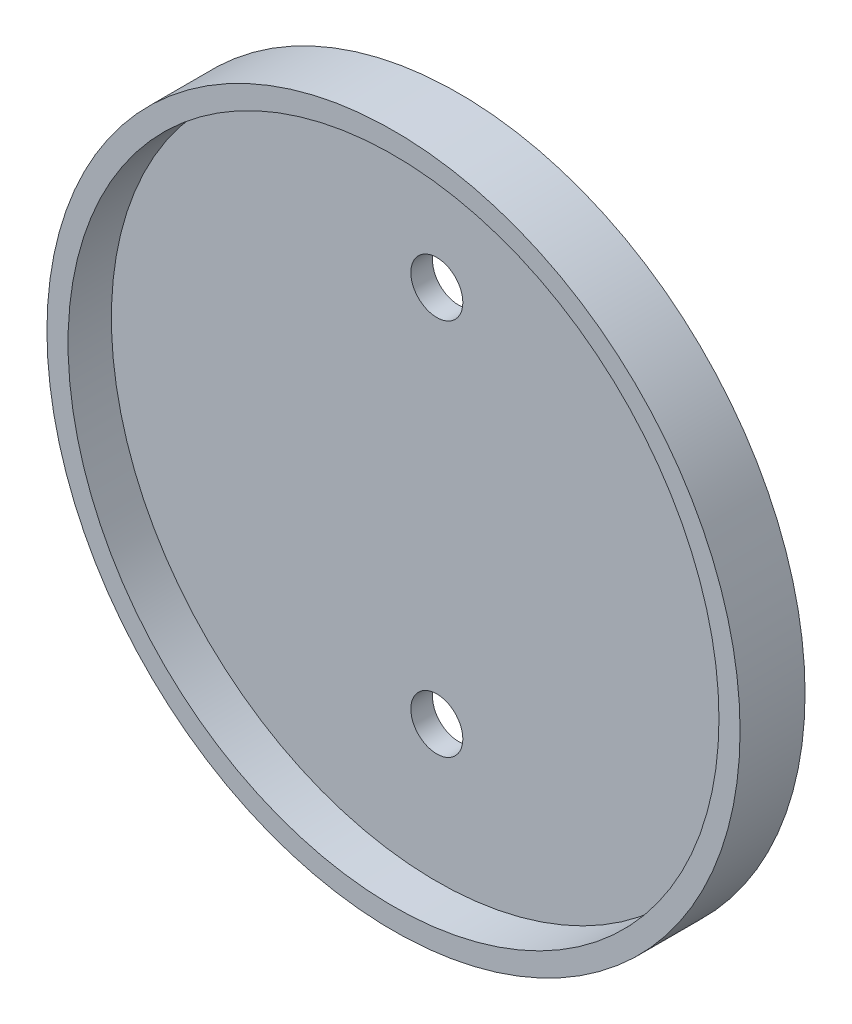
from build123d import *

# Parameters (mm, degrees)
SKETCH1_R                = 32
BOSS_EXTRUDE1_DEPTH      = 0.999998
SKETCH2_R                = 32
SKETCH2_R_2              = 30.05
BOSS_EXTRUDE2_DEPTH      = 4
M4_CLEARANCE_HOLE1_D     = 4.8
M4_CLEARANCE_HOLE1_DEPTH = 1.999996


with BuildPart() as part:
    # Sketch1 → Boss-Extrude1 (new body, symmetric)
    with BuildSketch(Plane.XY):
        Circle(SKETCH1_R)
    extrude(amount=BOSS_EXTRUDE1_DEPTH, both=True)

    # Sketch2 → Boss-Extrude2 (add)
    with BuildSketch(Plane.XY.offset(0.999998)):
        Circle(SKETCH2_R)
        Circle(SKETCH2_R_2, mode=Mode.SUBTRACT)
    extrude(amount=BOSS_EXTRUDE2_DEPTH)

    # M4 Clearance Hole1
    with Locations(Plane(origin=(0, 0, -0.999998), x_dir=(-1, 0, 0), z_dir=(0, 0, -1))):
        with Locations((0, 17.4498), (0, -17.4498)):
            Hole(M4_CLEARANCE_HOLE1_D / 2, depth=M4_CLEARANCE_HOLE1_DEPTH)


solid = part.part
